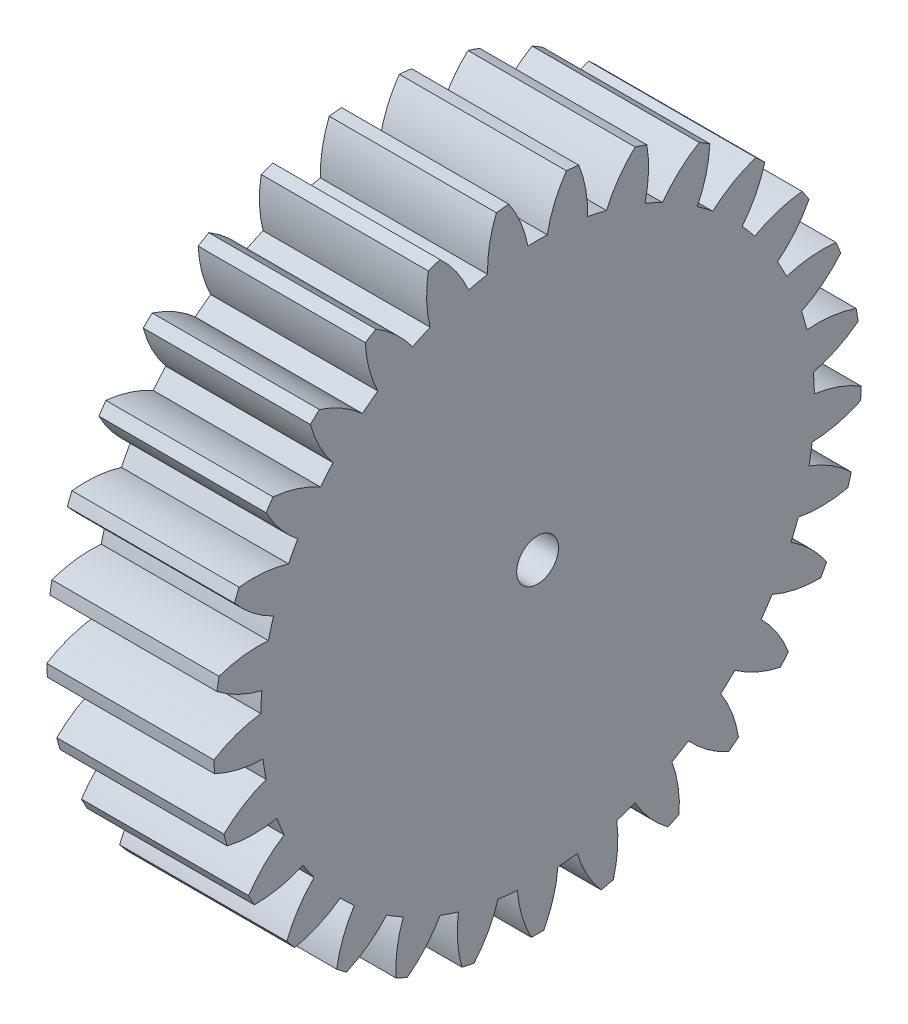
from build123d import *

# Parameters (mm, degrees)
BASPROSKE_W     = 20
BASPROSKE_H     = 38.75
TOOTHCUT_DEPTH  = 59.336309448
TEETHCUTS_COUNT = 29
TEETHCUTS_ANGLE = 347.586206897
BORSKE_R        = 2.5
BORE_DEPTH      = 50.0000508


with BuildPart() as part:
    # BasProSke → Base-Revolve (revolve)
    with BuildSketch(Plane(origin=(0, 0, 0), x_dir=(1, 0, 0), z_dir=(0, 1, 0)), mode=Mode.PRIVATE) as base_revolve_sk:
        with Locations((10, 19.375)):
            Rectangle(BASPROSKE_W, BASPROSKE_H)
    revolve(base_revolve_sk.sketch.rotate(Axis((-10, 0, 0), (1, 0, 0)), 180), axis=Axis((-10, 0, 0), (1, 0, 0)))

    # TooCutSke → ToothCut (cut, through all)
    with BuildSketch(Plane(origin=(0, 0, 0), x_dir=(0, 0, -1), z_dir=(1, 0, 0))):
        with BuildLine():
            ThreePointArc((1.159459794, 33.103701137), (0, 33.124), (-1.159459794, 33.103701137))
            ThreePointArc((-1.159459794, 33.103701137), (-2.026594281, 35.982160309), (-3.468658028, 38.619943768))
            ThreePointArc((-3.468658028, 38.619943768), (0, 38.7754), (3.468658028, 38.619943768))
            ThreePointArc((3.468658028, 38.619943768), (2.026594281, 35.982160309), (1.159459794, 33.103701137))
        make_face()
    toothcut = extrude(amount=TOOTHCUT_DEPTH, mode=Mode.SUBTRACT)

    # TeethCuts: ToothCut ×29 about axis
    teethcuts_axis = Axis((-10, 0, 0), (1, 0, 0))
    for i in range(1, TEETHCUTS_COUNT):
        add(toothcut.rotate(teethcuts_axis, i * TEETHCUTS_ANGLE / (TEETHCUTS_COUNT - 1)), mode=Mode.SUBTRACT)

    # BorSke → Bore (cut, symmetric)
    with BuildSketch(Plane(origin=(0, 0, 0), x_dir=(0, 0, -1), z_dir=(1, 0, 0))):
        with Locations(Location((0, 0, 0), (0, 0, 180))):
            Circle(BORSKE_R)
    extrude(amount=BORE_DEPTH, both=True, mode=Mode.SUBTRACT)


solid = part.part
